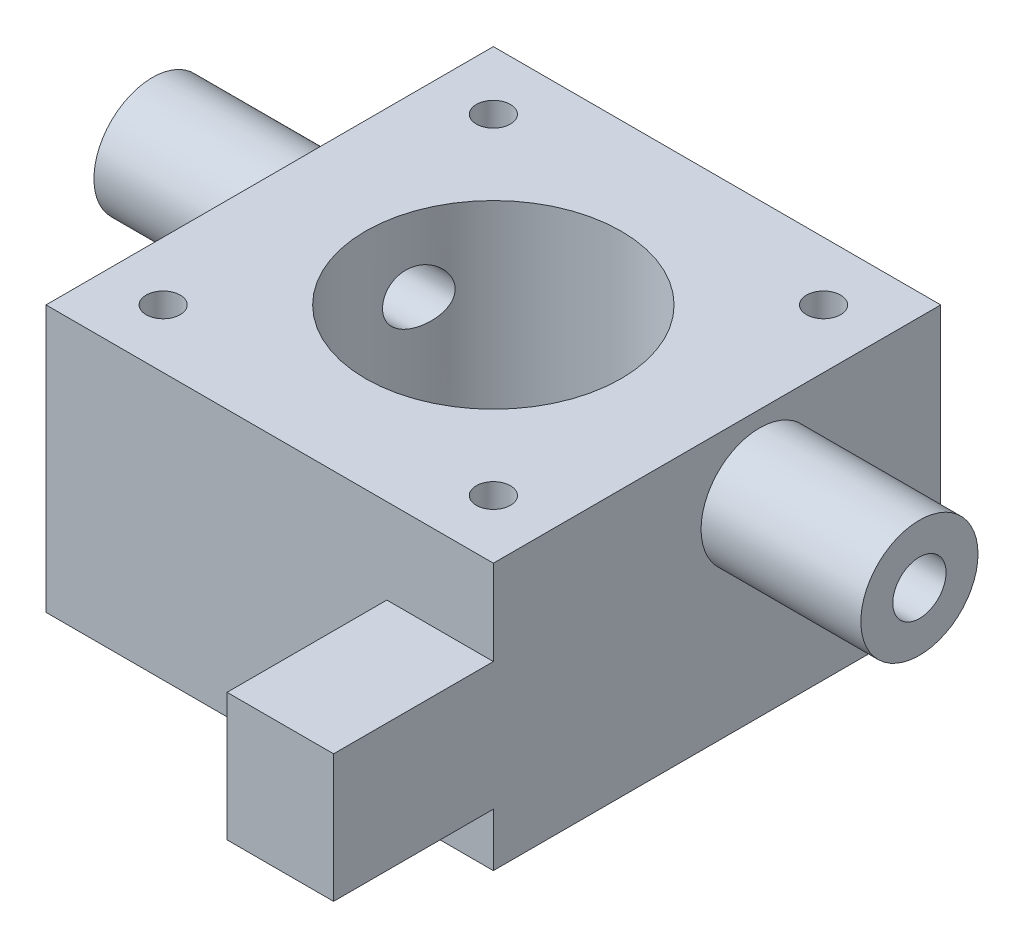
from build123d import *

# Parameters (mm, degrees)
SKETCH_1_W           = 42
SKETCH_1_H           = 42
EXTRUDE_1_DEPTH      = 25
SKETCH_2_W           = 10
SKETCH_2_H           = 12
EXTRUDE_2_DEPTH      = 15
SKETCH_3_R           = 5.5
EXTRUDE_3_DEPTH      = 15
EXTRUDE_3_DEPTH_BACK = 57
CUT_EXTRUDE_1_REACH  = 74
SKETCH_4_R           = 2.5
CUT_EXTRUDE_2_REACH  = 27
SKETCH_5_R           = 12
SKETCH_5_R_2         = 1.6


with BuildPart() as part:
    # 草图1 → 凸台-拉伸1 (new body)
    with BuildSketch(Plane(origin=(0, 0, 0), x_dir=(1, 0, 0), z_dir=(0, 1, 0))):
        Rectangle(SKETCH_1_W, SKETCH_1_H)
    extrude(amount=EXTRUDE_1_DEPTH)

    # 草图2 → 凸台-拉伸2 (add)
    with BuildSketch(Plane.XY.offset(21)):
        with Locations((16, 11)):
            Rectangle(SKETCH_2_W, SKETCH_2_H)
    extrude(amount=EXTRUDE_2_DEPTH)

    # 草图3 → 凸台-拉伸3 (add, two sides)
    with BuildSketch(Plane(origin=(21, 0, 0), x_dir=(0, 0, -1), z_dir=(1, 0, 0))) as extrude_3_sk:
        with Locations((4, 18)):
            Circle(SKETCH_3_R)
    extrude(amount=EXTRUDE_3_DEPTH)
    extrude(extrude_3_sk.sketch, amount=-EXTRUDE_3_DEPTH_BACK)

    # 草图4 → 切除-拉伸1 (cut, up to next)
    with BuildSketch(Plane(origin=(36, 0, 0), x_dir=(0, 0, -1), z_dir=(1, 0, 0)), mode=Mode.PRIVATE) as cut_extrude_1_sk1:
        with Locations((4, 18)):
            Circle(SKETCH_4_R)
    cut_extrude_1_tool1 = extrude(cut_extrude_1_sk1.sketch, amount=-CUT_EXTRUDE_1_REACH, mode=Mode.PRIVATE) & part.part
    add(cut_extrude_1_tool1.solids().sort_by_distance((36, 18, -4))[0], mode=Mode.SUBTRACT)

    # 草图5 → 切除-拉伸2 (cut, up to next)
    with BuildSketch(Plane(origin=(0, 25, 0), x_dir=(1, 0, 0), z_dir=(0, 1, 0)), mode=Mode.PRIVATE) as cut_extrude_2_sk1:
        Circle(SKETCH_5_R)
    cut_extrude_2_tool1 = extrude(cut_extrude_2_sk1.sketch, amount=-CUT_EXTRUDE_2_REACH, mode=Mode.PRIVATE) & part.part
    add(cut_extrude_2_tool1.solids().sort_by_distance((0, 25, 0))[0], mode=Mode.SUBTRACT)
    # 草图5 → 切除-拉伸2 (cut, up to next)
    with BuildSketch(Plane(origin=(0, 25, 0), x_dir=(1, 0, 0), z_dir=(0, 1, 0)), mode=Mode.PRIVATE) as cut_extrude_2_sk2:
        with Locations((-15.5, 15.5)):
            Circle(SKETCH_5_R_2)
    cut_extrude_2_tool2 = extrude(cut_extrude_2_sk2.sketch, amount=-CUT_EXTRUDE_2_REACH, mode=Mode.PRIVATE) & part.part
    add(cut_extrude_2_tool2.solids().sort_by_distance((-15.5, 25, -15.5))[0], mode=Mode.SUBTRACT)
    # 草图5 → 切除-拉伸2 (cut, up to next)
    with BuildSketch(Plane(origin=(0, 25, 0), x_dir=(1, 0, 0), z_dir=(0, 1, 0)), mode=Mode.PRIVATE) as cut_extrude_2_sk3:
        with Locations((15.5, 15.5)):
            Circle(SKETCH_5_R_2)
    cut_extrude_2_tool3 = extrude(cut_extrude_2_sk3.sketch, amount=-CUT_EXTRUDE_2_REACH, mode=Mode.PRIVATE) & part.part
    add(cut_extrude_2_tool3.solids().sort_by_distance((15.5, 25, -15.5))[0], mode=Mode.SUBTRACT)
    # 草图5 → 切除-拉伸2 (cut, up to next)
    with BuildSketch(Plane(origin=(0, 25, 0), x_dir=(1, 0, 0), z_dir=(0, 1, 0)), mode=Mode.PRIVATE) as cut_extrude_2_sk4:
        with Locations((15.5, -15.5)):
            Circle(SKETCH_5_R_2)
    cut_extrude_2_tool4 = extrude(cut_extrude_2_sk4.sketch, amount=-CUT_EXTRUDE_2_REACH, mode=Mode.PRIVATE) & part.part
    add(cut_extrude_2_tool4.solids().sort_by_distance((15.5, 25, 15.5))[0], mode=Mode.SUBTRACT)
    # 草图5 → 切除-拉伸2 (cut, up to next)
    with BuildSketch(Plane(origin=(0, 25, 0), x_dir=(1, 0, 0), z_dir=(0, 1, 0)), mode=Mode.PRIVATE) as cut_extrude_2_sk5:
        with Locations((-15.5, -15.5)):
            Circle(SKETCH_5_R_2)
    cut_extrude_2_tool5 = extrude(cut_extrude_2_sk5.sketch, amount=-CUT_EXTRUDE_2_REACH, mode=Mode.PRIVATE) & part.part
    add(cut_extrude_2_tool5.solids().sort_by_distance((-15.5, 25, 15.5))[0], mode=Mode.SUBTRACT)


solid = part.part
